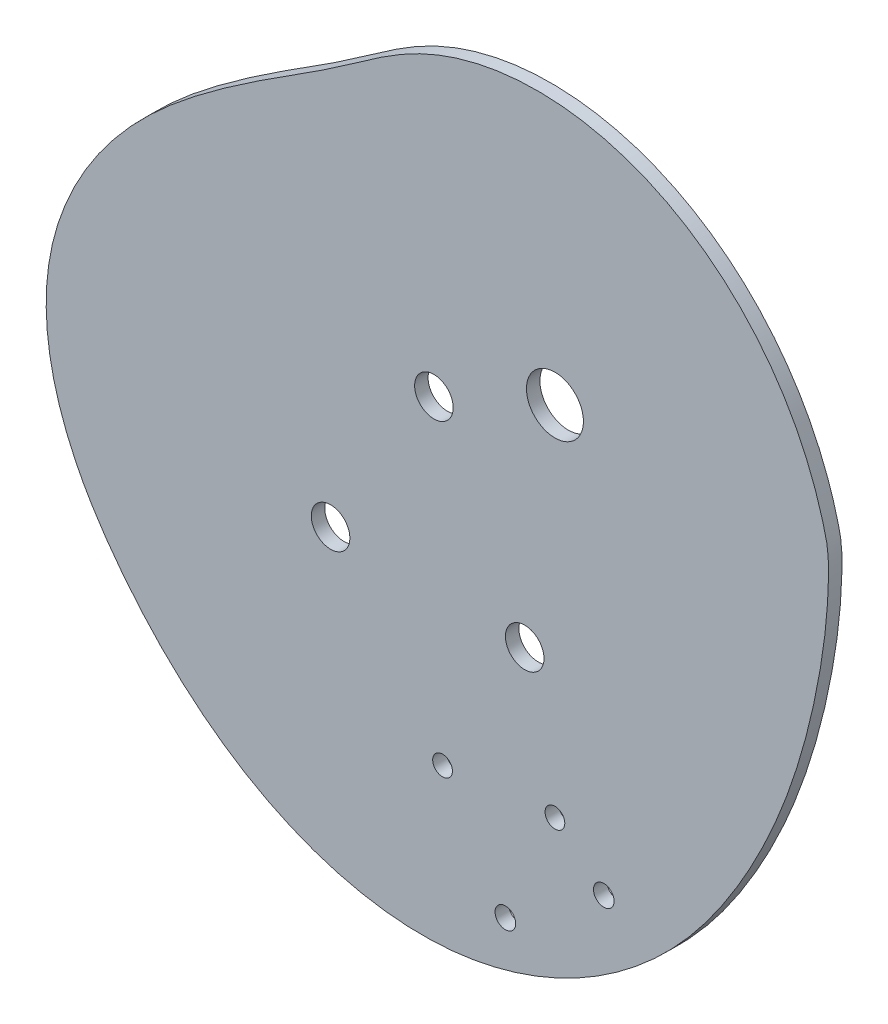
from build123d import *

# Parameters (mm, degrees)
SKETCH1_R               = 3.175
BOSS_EXTRUDE1_DEPTH     = 0.75
M4_CLEARANCE_HOLE1_D    = 4.3
CUT_EXTRUDE1_DEPTH      = 68.381846017
CUT_EXTRUDE1_DEPTH_BACK = 68.381846017
FILLET1_R               = 5
SKETCH10_R              = 1.5
BOSS_EXTRUDE5_DEPTH     = 0.75
SKETCH15_R              = 1.1
CUT_EXTRUDE3_DEPTH      = 10
SKETCH16_R              = 1.15
CUT_EXTRUDE4_DEPTH      = 10


with BuildPart() as part:
    # Sketch1 → Boss-Extrude1 (new, symmetric)
    with BuildSketch(Plane.XY):
        with BuildLine():
            add(Edge.make_bspline(
                [(20.469276515, 0), (20.453926982, 0.12032637), (20.37906939, 0.354674879), (20.296830063, 0.708499092), (20.201433403, 1.058274137), (20.104513169, 1.405451482), (20.003039964, 1.749648928), (19.897882185, 2.090972241), (19.788868962, 2.429397518), (19.676103633, 2.764935406), (19.559614296, 3.097587319), (19.439446847, 3.427357), (19.315640263, 3.754247363), (19.18823323, 4.078261244), (19.057262426, 4.399401123), (18.922763033, 4.717669117), (18.784768655, 5.033066908), (18.643311395, 5.345595684), (18.498421896, 5.655256084), (18.350129388, 5.962048143), (18.198461741, 6.265971239), (18.043445514, 6.567024042), (17.885106009, 6.865204466), (17.723467325, 7.160509621), (17.558552411, 7.452935769), (17.390383125, 7.742478283), (17.218980293, 8.029131604), (17.044363762, 8.312889204), (16.866552466, 8.593743551), (16.685564483, 8.871686073), (16.501417094, 9.146707128), (16.314126853, 9.418795975), (16.123709641, 9.687940747), (15.930180735, 9.954128423), (15.73355487, 10.21734481), (15.533846304, 10.477574522), (15.331068884, 10.734800958), (15.125236108, 10.989006292), (14.916361195, 11.240171456), (14.704457148, 11.48827613), (14.48953682, 11.733298735), (14.271612982, 11.975216425), (14.050698387, 12.214005082), (13.826805837, 12.449639318), (13.599948249, 12.682092471), (13.37013872, 12.911336613), (13.137390595, 13.137342549), (12.901717528, 13.360079832), (12.66313355, 13.579516764), (12.42165313, 13.795620417), (12.177291245, 14.00835664), (11.930063436, 14.21769008), (11.679985874, 14.423584196), (11.427075422, 14.626001285), (11.171349697, 14.824902501), (10.912827125, 15.020247881), (10.651527006, 15.211996372), (10.387469571, 15.400105862), (10.120676038, 15.584533205), (9.851168668, 15.765234263), (9.578970821, 15.942163933), (9.30410701, 16.115276188), (9.026602952, 16.284524115), (8.746485624, 16.449859953), (8.463783305, 16.611235142), (8.178525632, 16.768600359), (7.890743643, 16.921905569), (7.600469825, 17.071100071), (7.307738154, 17.216132546), (7.012584144, 17.356951111), (6.71504488, 17.493503366), (6.415159063, 17.625736452), (6.112967045, 17.753597106), (5.808510864, 17.877031712), (5.501834279, 17.995986365), (5.192982801, 18.110406928), (4.882003722, 18.22023909), (4.568946147, 18.32542843), (4.253861014, 18.425920478), (3.936801123, 18.521660778), (3.617821156, 18.612594954), (3.296977698, 18.698668773), (2.974329252, 18.779828214), (2.649936258, 18.856019533), (2.323861105, 18.927189329), (1.996168144, 18.993284617), (1.666923695, 19.054252892), (1.336196056, 19.110042202), (1.004055505, 19.160601215), (0.670574308, 19.205879292), (0.335826712, 19.245826554), (-0.000111049, 19.280393959), (-0.337160764, 19.309533366), (-0.675242249, 19.33319761), (-1.014273357, 19.351340575), (-1.354169986, 19.36391726), (-1.694846096, 19.370883857), (-2.036213723, 19.372197815), (-2.378182996, 19.367817918), (-2.720662158, 19.357704349), (-3.06355759, 19.341818766), (-3.406773832, 19.320124369), (-3.750213613, 19.29258597), (-4.093777879, 19.259170061), (-4.437365826, 19.219844885), (-4.780874932, 19.174580501), (-5.124200991, 19.123348854), (-5.467238158, 19.066123837), (-5.809878982, 19.002881361), (-6.152014452, 18.933599416), (-6.493534041, 18.858258136), (-6.834325754, 18.776839862), (-7.174276174, 18.689329199), (-7.513270515, 18.595713085), (-7.851192674, 18.49598084), (-8.187925289, 18.39012423), (-8.52334979, 18.278137522), (-8.857346463, 18.160017536), (-9.18979451, 18.035763705), (-9.520572102, 17.905378106), (-9.849556485, 17.76886559), (-10.176623887, 17.626233534), (-10.501650192, 17.477492989), (-10.824508724, 17.322654615), (-11.145080224, 17.161743427), (-11.463230747, 16.994735948), (-11.779050897, 16.821987195), (-12.092717082, 16.643916451), (-12.40442328, 16.460901436), (-12.714391967, 16.273307346), (-13.022869092, 16.08147821), (-13.330124311, 15.885737879), (-13.636449754, 15.686388462), (-13.942159146, 15.48370949), (-14.247586785, 15.277956924), (-14.553086511, 15.069362251), (-14.859030639, 14.858131599), (-15.165808852, 14.64444489), (-15.473827068, 14.428455032), (-15.783506277, 14.210287148), (-16.095281345, 13.990037832), (-16.40959979, 13.767774461), (-16.72692054, 13.54353453), (-17.047712658, 13.317325034), (-17.372454053, 13.089121892), (-17.701630161, 12.858869404), (-18.035732622, 12.62647976), (-18.375257928, 12.391832591), (-18.720706063, 12.15477456), (-19.072579127, 11.915119006), (-19.43137995, 11.672645633), (-19.797610697, 11.427100253), (-20.171771452, 11.17819457), (-20.554358808, 10.925606023), (-20.94586444, 10.668977684), (-21.346773666, 10.407918194), (-21.757564012, 10.14200177), (-22.178703761, 9.870768248), (-22.6106505, 9.593723189), (-23.053849668, 9.310338029), (-23.508733094, 9.020050289), (-23.975717536, 8.722263829), (-24.455203223, 8.416349151), (-24.947572399, 8.101643764), (-25.453187868, 7.777452583), (-25.972391547, 7.443048392), (-26.505503025, 7.097672347), (-27.052818136, 6.74053453), (-27.614607536, 6.370814557), (-28.191115299, 5.98766223), (-28.782557525, 5.590198235), (-29.389120965, 5.1775149), (-30.01096166, 4.74867698), (-30.64820362, 4.302722541), (-31.300937436, 3.838663708), (-31.969219271, 3.355488182), (-32.653068482, 2.852157975), (-33.352355561, 2.327705554), (-34.066325533, 1.781561053), (-34.792156176, 1.21198818), (-35.526433511, 0.617909195), (-36.265587734, -0.001457622), (-37.006020345, -0.646671842), (-37.744112291, -1.318073183), (-38.476233993, -2.015780313), (-39.198754785, -2.739691012), (-39.908052424, -3.489482365), (-40.600522516, -4.264611377), (-41.272587879, -5.064315898), (-41.920707839, -5.8876159), (-42.541387444, -6.733315094), (-43.131186577, -7.600002901), (-43.686728957, -8.486056757), (-44.204711001, -9.389644786), (-44.681910487, -10.308728765), (-45.115195144, -11.241067557), (-45.501530481, -12.184220343), (-45.837989248, -13.135551967), (-46.121753439, -14.092231719), (-46.350171981, -15.051382919), (-46.520731563, -16.010470183), (-46.635259313, -16.966833368), (-46.695881182, -17.918707922), (-46.704758414, -18.864589252), (-46.664077675, -19.803116927), (-46.576039325, -20.733069832), (-46.442852564, -21.653366621), (-46.266728948, -22.563064411), (-46.04987654, -23.461357639), (-45.794494099, -24.347576614), (-45.502765451, -25.221185937), (-45.176853985, -26.081782762), (-44.818897277, -26.929094921), (-44.431001821, -27.762978927), (-44.015237852, -28.583417844), (-43.57363427, -29.390519034), (-43.108173634, -30.184511764), (-42.620787267, -30.965744674), (-42.113350378, -31.734683158), (-41.587677508, -32.491906358), (-41.045517213, -33.238104962), (-40.488554103, -33.974069902), (-39.918413965, -34.700676565), (-39.33481729, -35.417341816), (-38.737534614, -36.123431266), (-38.126368953, -36.818284488), (-37.501156774, -37.501216811), (-36.861768424, -38.171521432), (-36.208109378, -38.828470556), (-35.54012122, -39.471316853), (-34.857782619, -40.099294871), (-34.161110261, -40.711622507), (-33.450159719, -41.307502509), (-32.725026287, -41.886124006), (-31.985845748, -42.446664075), (-31.232795105, -42.98828933), (-30.466093242, -43.510157547), (-29.686001549, -44.011419305), (-28.892824481, -44.491219662), (-28.08691006, -44.948699845), (-27.268650333, -45.382998964), (-26.438481761, -45.793255749), (-25.596885557, -46.178610297), (-24.744387965, -46.538205845), (-23.881560483, -46.871190547), (-23.009020024, -47.176719273), (-22.127429019, -47.45395541), (-21.237495463, -47.702072683), (-20.339972901, -47.920256977), (-19.435660354, -48.10770816), (-18.525402181, -48.263641942), (-17.610087896, -48.387291641), (-16.690651874, -48.477910274), (-15.768073177, -48.534771472), (-14.84337466, -48.55717479), (-13.917624463, -48.544434556), (-12.991941631, -48.495930985), (-12.067628664, -48.41094298), (-11.146068248, -48.290046351), (-10.228680944, -48.134143741), (-9.316882792, -47.944122816), (-8.412028473, -47.72093942), (-7.515412754, -47.465590968), (-6.62826823, -47.179120315), (-5.751764231, -46.862611411), (-4.88700552, -46.517187103), (-4.03503117, -46.144006323), (-3.196813506, -45.744261393), (-2.373257143, -45.319175263), (-1.565198119, -44.86999873), (-0.773403127, -44.398007635), (0.001431168, -43.904500034), (0.758678706, -43.390793354), (1.497784521, -42.858221534), (2.218265124, -42.308132156), (2.919708798, -41.74188356), (3.601775788, -41.160841961), (4.2641984, -40.566378558), (4.906780999, -39.959866645), (5.529399907, -39.342678725), (6.132003211, -38.716183626), (6.714610467, -38.081743631), (7.277312313, -37.440711615), (7.82026998, -36.794428197), (8.343714715, -36.144218914), (8.847947092, -35.491391398), (9.333336294, -34.837232621), (9.800319062, -34.183006019), (10.24939942, -33.529949158), (10.681145161, -32.879269558), (11.096195715, -32.232147378), (11.49523197, -31.589707036), (11.879149859, -30.952992781), (12.248517048, -30.322552069), (12.603694342, -29.698556098), (12.945153788, -29.0811272), (13.273344314, -28.470359529), (13.588713491, -27.866335339), (13.891701075, -27.269121707), (14.182740239, -26.678771864), (14.462256803, -26.095325337), (14.730669009, -25.518808409), (14.988387177, -24.949234509), (15.2358134, -24.386604625), (15.473341258, -23.830907716), (15.701355534, -23.282121139), (15.920231962, -22.740211075), (16.130336972, -22.205132959), (16.332027463, -21.676831916), (16.525650586, -21.155243203), (16.711543541, -20.640292652), (16.890033391, -20.131897115), (17.061436892, -19.629964916), (17.226060335, -19.134396296), (17.384199405, -18.645083873), (17.536139055, -18.161913089), (17.682153396, -17.684762669), (17.822505599, -17.213505075), (17.957447815, -16.748006957), (18.087221108, -16.288129613), (18.212055405, -15.833729436), (18.332169455, -15.384658369), (18.447770812, -14.940764355), (18.559055824, -14.501891782), (18.666209639, -14.067881928), (18.769406229, -13.638573405), (18.868808423, -13.213802595), (18.964567955, -12.793404083), (19.056825528, -12.37721109), (19.14571089, -11.965055896), (19.231342923, -11.556770257), (19.313829749, -11.152185827), (19.393268841, -10.751134561), (19.469747157, -10.353449118), (19.543341277, -9.95896326), (19.614117561, -9.567512236), (19.682132311, -9.178933172), (19.747431952, -8.793065437), (19.810053221, -8.409751015), (19.870023364, -8.028834861), (19.927360353, -7.650165254), (19.982073105, -7.273594135), (20.034161718, -6.898977439), (20.083617711, -6.526175422), (20.130424277, -6.15505297), (20.174556549, -5.785479904), (20.215981868, -5.417331275), (20.254660065, -5.050487643), (20.290543747, -4.684835353), (20.323578606, -4.320266795), (20.353703685, -3.956680655), (20.380851823, -3.593982143), (20.404949486, -3.232083278), (20.425918912, -2.87090287), (20.443671673, -2.510367615), (20.458134208, -2.150408957), (20.469154396, -1.790975662), (20.476850973, -1.431987855), (20.480314085, -1.073508931), (20.482447125, -0.715105964), (20.47192834, -0.358233383), (20.484273463, -0.11756243), (20.469276515, 0)],
                knots=[0, 0, 0, 0, 0.001764203, 0.003519492, 0.005266096, 0.007004244, 0.008734164, 0.010456082, 0.01217022, 0.013876802, 0.015576046, 0.017268173, 0.018953398, 0.020631935, 0.022303998, 0.023969797, 0.025629542, 0.027283438, 0.02893169, 0.030574501, 0.032212071, 0.033844598, 0.035472279, 0.037095307, 0.038713875, 0.04032817, 0.041938381, 0.043544692, 0.045147285, 0.046746342, 0.048342038, 0.04993455, 0.05152405, 0.053110709, 0.054694695, 0.056276173, 0.057855307, 0.059432256, 0.061007179, 0.062580232, 0.064151567, 0.065721335, 0.067289683, 0.068856757, 0.070422701, 0.071987653, 0.073551752, 0.075115133, 0.076677929, 0.078240269, 0.079802281, 0.08136409, 0.082925818, 0.084487586, 0.08604951, 0.087611705, 0.089174283, 0.090737355, 0.092301027, 0.093865405, 0.09543059, 0.096996683, 0.09856378, 0.100131977, 0.101701366, 0.103272038, 0.10484408, 0.106417578, 0.107992614, 0.109569269, 0.111147622, 0.112727748, 0.114309722, 0.115893614, 0.117479494, 0.11906743, 0.120657485, 0.122249722, 0.123844203, 0.125440984, 0.127040123, 0.128641672, 0.130245685, 0.13185221, 0.133461296, 0.135072989, 0.136687331, 0.138304365, 0.139924131, 0.141546665, 0.143172005, 0.144800184, 0.146431233, 0.148065183, 0.149702063, 0.151341898, 0.152984714, 0.154630532, 0.156279374, 0.157931258, 0.159586203, 0.161244224, 0.162905335, 0.164569548, 0.166236874, 0.167907321, 0.169580897, 0.171257607, 0.172937454, 0.174620442, 0.176306572, 0.177995841, 0.179688248, 0.181383788, 0.183082456, 0.184784246, 0.186489147, 0.188197151, 0.189908245, 0.191622417, 0.193339652, 0.195059933, 0.196783244, 0.198509566, 0.200238878, 0.201971181, 0.203706635, 0.205445504, 0.2071881, 0.208934793, 0.210686019, 0.212442285, 0.214204179, 0.215972379, 0.217747655, 0.219530879, 0.221323028, 0.223125194, 0.224938584, 0.226764524, 0.228604465, 0.230459983, 0.232332781, 0.234224685, 0.236137652, 0.238073757, 0.2400352, 0.242024293, 0.244043462, 0.246095238, 0.248182252, 0.250307226, 0.252472967, 0.254682362, 0.256938364, 0.259243991, 0.261602312, 0.264016447, 0.266489554, 0.269024826, 0.271625481, 0.274294763, 0.277035933, 0.279852264, 0.282747038, 0.285723547, 0.288785083, 0.291934943, 0.295176421, 0.298512813, 0.30194741, 0.305483503, 0.309124377, 0.312873317, 0.316733603, 0.320708513, 0.324801324, 0.329015309, 0.333351662, 0.33780314, 0.342360129, 0.347012767, 0.351751024, 0.35656476, 0.361443788, 0.366377916, 0.371356998, 0.376370977, 0.381409928, 0.386464106, 0.391523993, 0.396580347, 0.401624264, 0.406647238, 0.411641236, 0.416598779, 0.421513038, 0.426377942, 0.431188305, 0.435939966, 0.440631828, 0.445270717, 0.449864684, 0.454421044, 0.458946377, 0.463446541, 0.467926691, 0.472391308, 0.476844238, 0.481288728, 0.48572748, 0.490162693, 0.494596121, 0.499029126, 0.50346273, 0.507897674, 0.512334472, 0.516773466, 0.521214882, 0.525658883, 0.530105625, 0.534555313, 0.539008153, 0.543464074, 0.5479229, 0.552384417, 0.556848379, 0.561314515, 0.565782528, 0.570252105, 0.57472292, 0.579194639, 0.583666924, 0.588139439, 0.592611855, 0.597083853, 0.601555132, 0.606025412, 0.610494439, 0.614961992, 0.619427887, 0.623891985, 0.628354194, 0.632814475, 0.637272853, 0.641729416, 0.646184326, 0.650637823, 0.655090233, 0.659541971, 0.663993554, 0.668445597, 0.672898832, 0.677354104, 0.681812384, 0.68627477, 0.690742499, 0.695216754, 0.699697325, 0.704183213, 0.708673274, 0.713166232, 0.71766069, 0.722155137, 0.726647962, 0.731137456, 0.735621826, 0.7400992, 0.744567632, 0.749025113, 0.753469575, 0.757898896, 0.762310907, 0.766703399, 0.771074124, 0.775420805, 0.779741136, 0.784032793, 0.788293433, 0.792520702, 0.796712241, 0.800865688, 0.804978687, 0.809048891, 0.813073968, 0.817051612, 0.820979544, 0.824855525, 0.82867736, 0.832442913, 0.836150111, 0.839796963, 0.843381676, 0.84690413, 0.850365453, 0.853766802, 0.857109335, 0.860394205, 0.863622561, 0.866795554, 0.86991433, 0.872980033, 0.875993807, 0.878956793, 0.881870128, 0.88473495, 0.887552392, 0.890323587, 0.893049665, 0.895731754, 0.898370977, 0.900968457, 0.903525314, 0.906042661, 0.908521612, 0.910963275, 0.913368751, 0.915739141, 0.918075538, 0.920379029, 0.922650695, 0.924891611, 0.927102843, 0.929285451, 0.931440483, 0.93356898, 0.935671971, 0.937750475, 0.939805498, 0.941838034, 0.943849063, 0.945839551, 0.947810449, 0.949762689, 0.95169719, 0.953614851, 0.955516554, 0.957403159, 0.959275508, 0.961134423, 0.962980703, 0.964815124, 0.966638443, 0.96845139, 0.970254675, 0.972048981, 0.973834969, 0.975613274, 0.977384508, 0.979149256, 0.980908081, 0.982661518, 0.984410078, 0.98615425, 0.987894493, 0.989631248, 0.991364926, 0.993095918, 0.994824589, 0.996551283, 0.998276321, 1, 1, 1, 1], degree=3))
        make_face()
        Circle(SKETCH1_R, mode=Mode.SUBTRACT)
    extrude(amount=BOSS_EXTRUDE1_DEPTH, both=True)

    # M4 Clearance Hole1 (through all)
    with Locations(Plane.XY.offset(0.75)):
        with Locations((-13.488047982, -5.9360377), (-3.367538379, -25.076378767), (-25.003814781, -24.270826649)):
            Hole(M4_CLEARANCE_HOLE1_D / 2)

    # Sketch8 → Cut-Extrude1 (cut, two sides)
    with BuildSketch(Plane.XY.offset(0.75)) as cut_extrude1_sk:
        with BuildLine():
            Line((-11.626551218, -28.678548558), (-13.178933471, -40.002638338))
            Line((-13.178933471, -40.002638338), (-17.34001633, -39.432209163))
            Line((-17.34001633, -39.432209163), (-18.925848035, -49.669625904))
            Line((-18.925848035, -49.669625904), (-20.50262579, -49.477417695))
            Line((-20.50262579, -49.477417695), (-17.155731532, -27.871372615))
            ThreePointArc((-17.155731532, -27.871372615), (-13.991058725, -25.534381995), (-11.626551218, -28.678548558))
        make_face()
    extrude(amount=CUT_EXTRUDE1_DEPTH, mode=Mode.SUBTRACT)
    extrude(cut_extrude1_sk.sketch, amount=-CUT_EXTRUDE1_DEPTH_BACK, mode=Mode.SUBTRACT)

    # Fillet1
    fillet1_edges = [part.edges().sort_by_distance(p)[0] for p in [
        (-20.263238561, -47.932041336, 0.3749997),
    ]]
    fillet(fillet1_edges, radius=FILLET1_R)

    # Sketch10 → Boss-Extrude5 (add, symmetric)
    with BuildSketch(Plane.XY):
        with BuildLine():
            add(Edge.make_bspline(
                [(-53.421193613, -32.13028295), (-52.178904881, -34.687532482), (-50.674980335, -37.04456853), (-48.179415993, -40.396712419), (-47.309972351, -41.485329316), (-45.49275561, -43.602622489), (-44.544259982, -44.630745857), (-42.558260151, -46.618879913), (-41.515493842, -47.582942645), (-39.370332741, -49.401613868), (-38.26568709, -50.259273035), (-34.851505468, -52.670695198), (-32.442809183, -54.064650416), (-29.241055989, -55.499465701), (-28.591076001, -55.770909999), (-27.270813769, -56.281079273), (-26.601209391, -56.519372943), (-24.587657751, -57.174347575), (-23.230525047, -57.534683766), (-20.485958518, -58.098742859), (-19.098534353, -58.30251569), (-16.993288455, -58.483562656), (-16.287512117, -58.523094188), (-14.867537255, -58.558626647), (-14.159224854, -58.554415926), (-10.639169145, -58.424294206), (-7.878500088, -57.969681073), (-4.491184618, -56.999340534), (-3.815603429, -56.784486675), (-2.476844424, -56.316202204), (-1.816867653, -56.063988292), (0.136061887, -55.255452145), (1.402095962, -54.64739325), (3.866387913, -53.301012302), (5.064622373, -52.562645242), (6.812360394, -51.359739153), (7.387246843, -50.942285651), (8.509873033, -50.084127243), (9.058981918, -49.642534921), (11.745830051, -47.374391329), (13.70830583, -45.368140398), (15.952479455, -42.64611752), (16.391679402, -42.089830253), (17.245330642, -40.962326389), (17.659346699, -40.391801192), (18.8658489, -38.661430094), (19.622537708, -37.482655769), (21.778859021, -33.88618822), (23.064013754, -31.407963015), (24.763498846, -27.569935896), (25.291983578, -26.270494961), (26.27407731, -23.63202133), (26.728094486, -22.29089094), (27.968979753, -18.2557527), (28.643076203, -15.536489989), (29.453261936, -11.419321777), (29.689401997, -10.040471701), (30.082535085, -7.2676974), (30.239411021, -5.873750874), (30.394989864, -3.767644942), (30.433473508, -3.063062077), (30.46777126, -2.001725794), (30.475179898, -1.646968244), (30.480258749, -1.116523824), (30.481638678, -0.939764375), (30.480583722, -0.675177838), (30.4796686, -0.587081977), (30.476868648, -0.411061749), (30.47873359, -0.322474227), (30.481718674, 0.472373014), (30.422732686, 1.168002849), (30.235628565, 2.194005558), (30.156974777, 2.533126294), (30.018309709, 3.038149326), (29.977957122, 3.207528299), (29.888923119, 3.544813275), (29.842503503, 3.713119282), (29.607746332, 4.554179051), (29.401222005, 5.223716448), (28.949117269, 6.555884099), (28.703971786, 7.217122843), (27.918754974, 9.166219452), (27.326545196, 10.427246131), (26.004378118, 12.872398976), (25.274444431, 14.056538325), (24.071706984, 15.772545075), (23.652774811, 16.334487445), (22.777470789, 17.437470682), (22.322564945, 17.976427052), (19.984967451, 20.581492565), (17.895408381, 22.408589004), (14.995952876, 24.355863079), (14.401489192, 24.728257142), (13.182213307, 25.437514949), (12.562149845, 25.771503787), (10.682297151, 26.706280167), (9.398231442, 27.242892846), (6.768607885, 28.143449668), (5.423064679, 28.507434926), (3.356441355, 28.917763597), (2.657153431, 29.032019616), (1.263120521, 29.210954781), (0.566429753, 29.276180605), (-1.522681413, 29.40031803), (-2.914144962, 29.388008846), (-4.999410066, 29.225873624), (-5.694175676, 29.147804732), (-7.083045382, 28.942428872), (-7.77986247, 28.814429412), (-11.214973816, 28.057826164), (-13.824996527, 27.085951662), (-16.915270201, 25.413740203), (-17.526034309, 25.056102551), (-18.722569329, 24.313386897), (-19.30984263, 23.927576271), (-21.052187753, 22.74454318), (-22.188661507, 21.922872014), (-23.914075675, 20.717581779), (-24.492489105, 20.320124118), (-25.658044047, 19.536682585), (-26.245040443, 19.150507943), (-28.014158863, 18.002670571), (-29.203639764, 17.250681694), (-31.572652145, 15.7336246), (-32.752206605, 14.968586592), (-35.085403792, 13.404447456), (-36.239259419, 12.605626202), (-38.514240526, 10.964957204), (-39.636928972, 10.125164106), (-41.838670916, 8.388216156), (-42.915546753, 7.488198587), (-45.003373601, 5.601499799), (-46.014647868, 4.615243527), (-47.472093462, 3.057686387), (-47.947999932, 2.52547483), (-48.878045179, 1.432436278), (-49.333609865, 0.86972473), (-50.6531726, -0.851205129), (-51.46686682, -2.036868562), (-52.948660962, -4.49283549), (-53.616947063, -5.763030752), (-54.493989274, -7.741216324), (-54.766317374, -8.415646313), (-55.259117414, -9.77446119), (-55.479783411, -10.458619326), (-56.06191484, -12.52583771), (-56.342048808, -13.923912367), (-56.593854276, -16.052111446), (-56.650017436, -16.766638061), (-56.706162129, -18.206062849), (-56.705912938, -18.934372508), (-56.620717477, -21.103889766), (-56.453069121, -22.530656444), (-55.914943246, -25.348366866), (-55.544288423, -26.739279294), (-54.844474987, -28.800245003), (-54.588760691, -29.478366128), (-54.173939186, -30.482341862), (-53.95869054, -30.981092252), (-53.694286854, -31.557482231), (-53.578171425, -31.803350135), (-53.500144069, -31.967007188), (-53.460015136, -32.050368902), (-53.421193613, -32.13028295)],
                knots=[0, 0, 0, 0, 0.03125, 0.03125, 0.046875, 0.046875, 0.0625, 0.0625, 0.078125, 0.078125, 0.09375, 0.09375, 0.125, 0.125, 0.1328125, 0.1328125, 0.140625, 0.140625, 0.15625, 0.15625, 0.171875, 0.171875, 0.1796875, 0.1796875, 0.1875, 0.1875, 0.21875, 0.21875, 0.2265625, 0.2265625, 0.234375, 0.234375, 0.25, 0.25, 0.265625, 0.265625, 0.2734375, 0.2734375, 0.28125, 0.28125, 0.3125, 0.3125, 0.3203125, 0.3203125, 0.328125, 0.328125, 0.34375, 0.34375, 0.375, 0.375, 0.390625, 0.390625, 0.40625, 0.40625, 0.4375, 0.4375, 0.453125, 0.453125, 0.46875, 0.46875, 0.4765625, 0.4765625, 0.48046875, 0.48046875, 0.482421875, 0.482421875, 0.483398438, 0.483398438, 0.484375, 0.484375, 0.4921875, 0.4921875, 0.49609375, 0.49609375, 0.498046875, 0.498046875, 0.5, 0.5, 0.5078125, 0.5078125, 0.515625, 0.515625, 0.53125, 0.53125, 0.546875, 0.546875, 0.5546875, 0.5546875, 0.5625, 0.5625, 0.59375, 0.59375, 0.6015625, 0.6015625, 0.609375, 0.609375, 0.625, 0.625, 0.640625, 0.640625, 0.6484375, 0.6484375, 0.65625, 0.65625, 0.671875, 0.671875, 0.6796875, 0.6796875, 0.6875, 0.6875, 0.71875, 0.71875, 0.7265625, 0.7265625, 0.734375, 0.734375, 0.75, 0.75, 0.7578125, 0.7578125, 0.765625, 0.765625, 0.78125, 0.78125, 0.796875, 0.796875, 0.8125, 0.8125, 0.828125, 0.828125, 0.84375, 0.84375, 0.859375, 0.859375, 0.8671875, 0.8671875, 0.875, 0.875, 0.890625, 0.890625, 0.90625, 0.90625, 0.9140625, 0.9140625, 0.921875, 0.921875, 0.9375, 0.9375, 0.9453125, 0.9453125, 0.953125, 0.953125, 0.96875, 0.96875, 0.984375, 0.984375, 0.9921875, 0.9921875, 0.99609375, 0.998046875, 0.999023438, 0.999023438, 1, 1, 1, 1], degree=3))
        make_face()
        with Locations((-13.044208592, -46.058777765)):
            Circle(SKETCH10_R, mode=Mode.SUBTRACT)
        with BuildLine():
            Line((-8.517668676, -31.446433191), (-10.321369811, -44.603806992))
            ThreePointArc((-10.321369811, -44.603806992), (-9.450258988, -46.859503108), (-7.076961298, -47.322598249))
            add(Edge.make_bspline(
                [(-7.076961298, -47.322598249), (-6.927507698, -47.274382797), (-6.483682082, -47.126909711), (-5.751764231, -46.862611411), (-4.88700552, -46.517187103), (-4.03503117, -46.144006323), (-3.196813506, -45.744261393), (-2.373257143, -45.319175263), (-1.565198119, -44.86999873), (-0.773403127, -44.398007635), (0.001431168, -43.904500034), (0.758678706, -43.390793354), (1.497784521, -42.858221534), (2.218265124, -42.308132156), (2.919708798, -41.74188356), (3.601775788, -41.160841961), (4.2641984, -40.566378558), (4.906780999, -39.959866645), (5.529399907, -39.342678725), (6.132003211, -38.716183626), (6.714610467, -38.081743631), (7.277312313, -37.440711615), (7.82026998, -36.794428197), (8.343714715, -36.144218914), (8.847947092, -35.491391398), (9.333336294, -34.837232621), (9.800319062, -34.183006019), (10.24939942, -33.529949158), (10.681145161, -32.879269558), (11.096195715, -32.232147378), (11.49523197, -31.589707036), (11.879149859, -30.952992781), (12.484214789, -29.920260106), (13.16182615, -28.695622383), (13.889971522, -27.281095479), (14.460758303, -26.106790973), (14.987096627, -24.960193237), (15.472237208, -23.841361435), (15.919294921, -22.750162435), (16.396086226, -21.518813933), (16.888459697, -20.155129873), (17.434004753, -18.513070842), (17.912114427, -16.92954554), (18.33190322, -15.401570822), (18.63095177, -14.222303383), (18.868915787, -13.219040616), (19.057016984, -12.382028019), (19.23162101, -11.561179373), (19.393636904, -10.755150146), (19.543803302, -9.962600593), (19.682692651, -9.182208413), (19.810716354, -8.412681058), (19.928130654, -7.652767556), (20.035043266, -6.901269809), (20.131420692, -6.15705335), (20.217096193, -5.419057509), (20.291778369, -4.686304953), (20.355060273, -3.957910582), (20.406428762, -3.233089766), (20.438830624, -2.630856685), (20.458134208, -2.150408957), (20.469154396, -1.790975662), (20.476850973, -1.431987855), (20.480314085, -1.073508931), (20.482447125, -0.715105964), (20.47192834, -0.358233383), (20.490588655, 0.005553662), (20.37906939, 0.354674879), (20.296830063, 0.708499092), (20.201433403, 1.058274137), (20.104513169, 1.405451482), (20.003039964, 1.749648928), (19.897882185, 2.090972241), (19.716978938, 2.652575959), (19.370322677, 3.642869613), (18.847171735, 4.926667497), (18.210388788, 6.266149682), (17.569997694, 7.454376552), (16.877476061, 8.596391973), (16.134073485, 9.691741469), (15.340836903, 10.739699025), (14.498674159, 11.739239018), (13.608420947, 12.689019588), (12.670908224, 13.587374806), (11.687029555, 14.432316504), (10.743710817, 15.155672549), (9.854199094, 15.770632381), (9.029307409, 16.290210305), (8.180894388, 16.774556194), (7.309762112, 17.222339333), (6.416829246, 17.632175059), (5.503142056, 18.002637241), (4.569883247, 18.332271585), (3.618379757, 18.619609951), (2.650109046, 18.863185491), (1.666703947, 19.061548493), (0.669955957, 19.213282792), (-0.338183051, 19.317022624), (-1.355600742, 19.371469761), (-2.380025888, 19.375410809), (-3.409031599, 19.327734507), (-4.440040221, 19.227448878), (-5.470329898, 19.073698103), (-6.497042762, 18.865778957), (-7.517194735, 18.603156671), (-8.52768688, 18.285480077), (-9.525318242, 17.912595864), (-10.287353367, 17.580266708), (-10.824508724, 17.322654615), (-11.145080224, 17.161743427), (-11.463230747, 16.994735948), (-11.884752183, 16.764170221), (-12.406394521, 16.46253457), (-13.024815244, 16.082593241), (-13.638406214, 15.686970101), (-14.249606489, 15.277982893), (-14.757868668, 14.928596084), (-15.269394129, 14.572292449), (-15.681110202, 14.282623482), (-16.095281345, 13.990037832), (-16.40959979, 13.767774461), (-16.72692054, 13.54353453), (-17.047712658, 13.317325034), (-17.372454053, 13.089121892), (-17.701630161, 12.858869404), (-18.035732622, 12.62647976), (-18.375257928, 12.391832591), (-18.720706063, 12.15477456), (-19.072579127, 11.915119006), (-19.43137995, 11.672645633), (-19.924481592, 11.342037591), (-20.562017155, 10.919650525), (-21.355586298, 10.401414838), (-22.339808024, 9.76625939), (-23.376506165, 9.104221291), (-24.468470792, 8.408160324), (-25.289493847, 7.882883205), (-25.972391547, 7.443048392), (-26.505503025, 7.097672347), (-27.052818136, 6.74053453), (-27.614607536, 6.370814557), (-28.191115299, 5.98766223), (-28.782557525, 5.590198235), (-29.389120965, 5.1775149), (-30.01096166, 4.74867698), (-30.64820362, 4.302722541), (-31.300937436, 3.838663708), (-32.205313194, 3.184789533), (-33.127606674, 2.499625066), (-34.066325533, 1.781561053), (-34.792156176, 1.21198818), (-35.526433511, 0.617909195), (-36.265587734, -0.001457622), (-37.006020345, -0.646671842), (-37.744112291, -1.318073183), (-38.476233993, -2.015780313), (-39.198754785, -2.739691012), (-39.908052424, -3.489482365), (-40.600522516, -4.264611377), (-41.272587879, -5.064315898), (-41.920707839, -5.8876159), (-42.541387444, -6.733315094), (-43.131186577, -7.600002901), (-43.686728957, -8.486056757), (-44.204711001, -9.389644786), (-44.681910487, -10.308728765), (-45.115195144, -11.241067557), (-45.501530481, -12.184220343), (-45.837989248, -13.135551967), (-46.121753439, -14.092231719), (-46.350171981, -15.051382919), (-46.520731563, -16.010470183), (-46.635259313, -16.966833368), (-46.695881182, -17.918707922), (-46.704758414, -18.864589252), (-46.664077675, -19.803116927), (-46.576039325, -20.733069832), (-46.442852564, -21.653366621), (-46.266728948, -22.563064411), (-46.04987654, -23.461357639), (-45.794494099, -24.347576614), (-45.502765451, -25.221185937), (-45.176853985, -26.081782762), (-44.818897277, -26.929094921), (-44.431001821, -27.762978927), (-44.015237852, -28.583417844), (-43.57363427, -29.390519034), (-43.108173634, -30.184511764), (-42.620787267, -30.965744674), (-42.113350378, -31.734683158), (-41.587677508, -32.491906358), (-41.045517213, -33.238104962), (-40.488554103, -33.974069902), (-39.72811077, -34.943205657), (-38.941004715, -35.892099789), (-38.126368953, -36.818284488), (-37.501156774, -37.501216811), (-36.861768424, -38.171521432), (-36.208109378, -38.828470556), (-35.54012122, -39.471316853), (-34.857782619, -40.099294871), (-34.161110261, -40.711622507), (-33.450159719, -41.307502509), (-32.725026287, -41.886124006), (-31.985845748, -42.446664075), (-31.232795105, -42.98828933), (-30.466093242, -43.510157547), (-29.686001549, -44.011419305), (-28.892824481, -44.491219662), (-28.08691006, -44.948699845), (-27.252884073, -45.391367056), (-26.683078326, -45.672363134), (-26.388034079, -45.812156396)],
                knots=[0.719883787, 0.719883787, 0.719883787, 0.719883787, 0.722155137, 0.726647962, 0.731137456, 0.735621826, 0.7400992, 0.744567632, 0.749025113, 0.753469575, 0.757898896, 0.762310907, 0.766703399, 0.771074124, 0.775420805, 0.779741136, 0.784032793, 0.788293433, 0.792520702, 0.796712241, 0.800865688, 0.804978687, 0.809048891, 0.813073968, 0.817051612, 0.820979544, 0.824855525, 0.82867736, 0.832442913, 0.836150111, 0.839796963, 0.843381676, 0.84690413, 0.857109335, 0.863622561, 0.86991433, 0.875993807, 0.881870128, 0.887552392, 0.893049665, 0.900968457, 0.908521612, 0.918075538, 0.924891611, 0.931440483, 0.935671971, 0.939805498, 0.943849063, 0.947810449, 0.95169719, 0.955516554, 0.959275508, 0.962980703, 0.966638443, 0.970254675, 0.973834969, 0.977384508, 0.980908081, 0.984410078, 0.987894493, 0.989631248, 0.991364926, 0.993095918, 0.994824589, 0.996551283, 0.998276321, 1, 1.001764203, 1.003519492, 1.005266096, 1.007004244, 1.008734164, 1.010456082, 1.01217022, 1.017268173, 1.025629542, 1.032212071, 1.038713875, 1.045147285, 1.05152405, 1.057855307, 1.064151567, 1.070422701, 1.076677929, 1.082925818, 1.089174283, 1.093865405, 1.09856378, 1.103272038, 1.107992614, 1.112727748, 1.117479494, 1.122249722, 1.127040123, 1.13185221, 1.136687331, 1.141546665, 1.146431233, 1.151341898, 1.156279374, 1.161244224, 1.166236874, 1.171257607, 1.176306572, 1.181383788, 1.186489147, 1.191622417, 1.196783244, 1.198509566, 1.200238878, 1.201971181, 1.203706635, 1.2071881, 1.210686019, 1.214204179, 1.217747655, 1.221323028, 1.223125194, 1.226764524, 1.228604465, 1.230459983, 1.232332781, 1.234224685, 1.236137652, 1.238073757, 1.2400352, 1.242024293, 1.244043462, 1.246095238, 1.248182252, 1.250307226, 1.254682362, 1.259243991, 1.264016447, 1.271625481, 1.277035933, 1.282747038, 1.285723547, 1.288785083, 1.291934943, 1.295176421, 1.298512813, 1.30194741, 1.305483503, 1.309124377, 1.312873317, 1.316733603, 1.320708513, 1.329015309, 1.333351662, 1.33780314, 1.342360129, 1.347012767, 1.351751024, 1.35656476, 1.361443788, 1.366377916, 1.371356998, 1.376370977, 1.381409928, 1.386464106, 1.391523993, 1.396580347, 1.401624264, 1.406647238, 1.411641236, 1.416598779, 1.421513038, 1.426377942, 1.431188305, 1.435939966, 1.440631828, 1.445270717, 1.449864684, 1.454421044, 1.458946377, 1.463446541, 1.467926691, 1.472391308, 1.476844238, 1.481288728, 1.48572748, 1.490162693, 1.494596121, 1.499029126, 1.50346273, 1.507897674, 1.512334472, 1.516773466, 1.521214882, 1.525658883, 1.530105625, 1.534555313, 1.539008153, 1.5479229, 1.552384417, 1.556848379, 1.561314515, 1.565782528, 1.570252105, 1.57472292, 1.579194639, 1.583666924, 1.588139439, 1.592611855, 1.597083853, 1.601555132, 1.606025412, 1.610494439, 1.614961992, 1.619427887, 1.62415013, 1.62415013, 1.62415013, 1.62415013], degree=3))
            ThreePointArc((-26.388034079, -45.812156396), (-24.127722984, -45.751598541), (-22.840761415, -43.892458035))
            Line((-22.840761415, -43.892458035), (-20.901843851, -29.748727315))
            ThreePointArc((-20.901843851, -29.748727315), (-13.860903325, -24.405492666), (-8.517668676, -31.446433191))
        make_face(mode=Mode.SUBTRACT)
    extrude(amount=BOSS_EXTRUDE5_DEPTH, both=True)

    # Sketch15 → Cut-Extrude3 (cut)
    with BuildSketch(Plane.XY.offset(0.75)):
        with Locations((-12.52460351, -41.04915847)):
            Circle(SKETCH15_R)
        with Locations((0, -39.8190457)):
            Circle(SKETCH15_R)
    extrude(amount=-CUT_EXTRUDE3_DEPTH, mode=Mode.SUBTRACT)

    # Sketch16 → Cut-Extrude4 (cut)
    with BuildSketch(Plane.XY.offset(0.75)):
        with Locations((-5.52301951, -52.247407725)):
            Circle(SKETCH16_R)
        with Locations((5.444897507, -44.593507485)):
            Circle(SKETCH16_R)
    extrude(amount=-CUT_EXTRUDE4_DEPTH, mode=Mode.SUBTRACT)


solid = part.part
